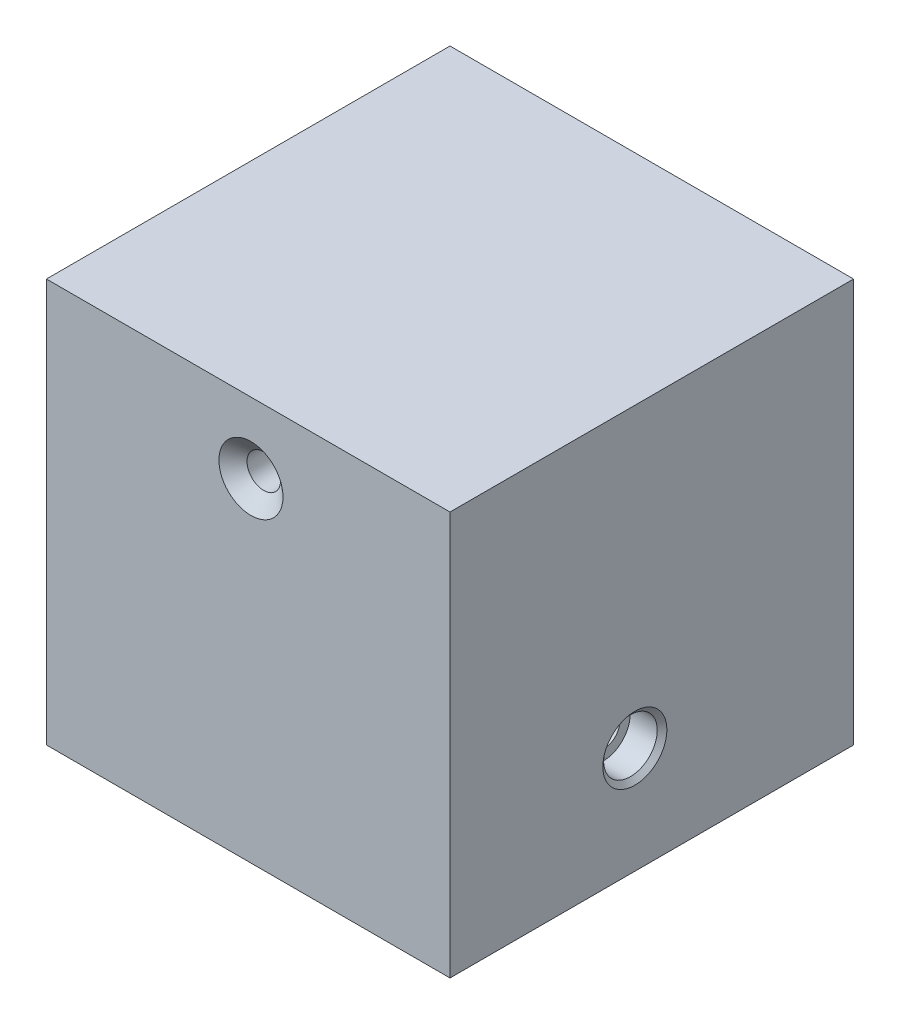
from build123d import *

# Parameters (mm, degrees)
SKETCH1_W           = 101.6
SKETCH1_H           = 101.6
BOSS_EXTRUDE1_DEPTH = 101.6
SKETCH6_R           = 6.922774564
CUT_EXTRUDE1_DEPTH  = 12.7
CHAMFER2_SIZE       = 2.54


with BuildPart() as part:
    # Sketch1 → Boss-Extrude1 (new body)
    with BuildSketch(Plane.XY):
        with Locations((50.8, 50.8)):
            Rectangle(SKETCH1_W, SKETCH1_H)
    extrude(amount=BOSS_EXTRUDE1_DEPTH)

    # Sketch3 → CSK for 5/16 Flat Head Machine Screw (100)1 (revolve, cut)
    with BuildSketch(Plane(origin=(51.490087233, 83.841482184, 101.6), x_dir=(0, -1, 0), z_dir=(1, 0, 0))):
        Polygon((0, 0), (0, 101.6), (8.0645, 101.6), (4.2164, 98.371060709), (4.2164, 3.228939291), (8.0645, 0), align=None)
    revolve(axis=Axis((51.490087233, 83.841482184, 107.95), (0, 0, -1)), mode=Mode.SUBTRACT)

    # Sketch5 → CBORE for 5/16 Socket Head Cap Screw1 (revolve, cut)
    with BuildSketch(Plane(origin=(101.6, 26.823245181, 55.06253419), x_dir=(0, 0, -1), z_dir=(0, 1, 0))):
        Polygon((0, 0), (0, 101.6), (4.2164, 101.6), (4.2164, 7.9375), (6.74751, 7.9375), (6.74751, 1.105085823), (8.0645, 0), align=None)
    revolve(axis=Axis((107.95, 26.823245181, 55.06253419), (-1, 0, 0)), mode=Mode.SUBTRACT)

    # Sketch6 → Cut-Extrude1 (cut)
    with BuildSketch(Plane.ZY):
        with Locations((55.06253419, 26.823245181)):
            Circle(SKETCH6_R)
    extrude(amount=-CUT_EXTRUDE1_DEPTH, mode=Mode.SUBTRACT)

    # Chamfer2
    chamfer2_edges = [part.edges().sort_by_distance(p)[0] for p in [
        (0, 26.823245181, 48.139759626),
    ]]
    chamfer(chamfer2_edges, length=CHAMFER2_SIZE)


solid = part.part
